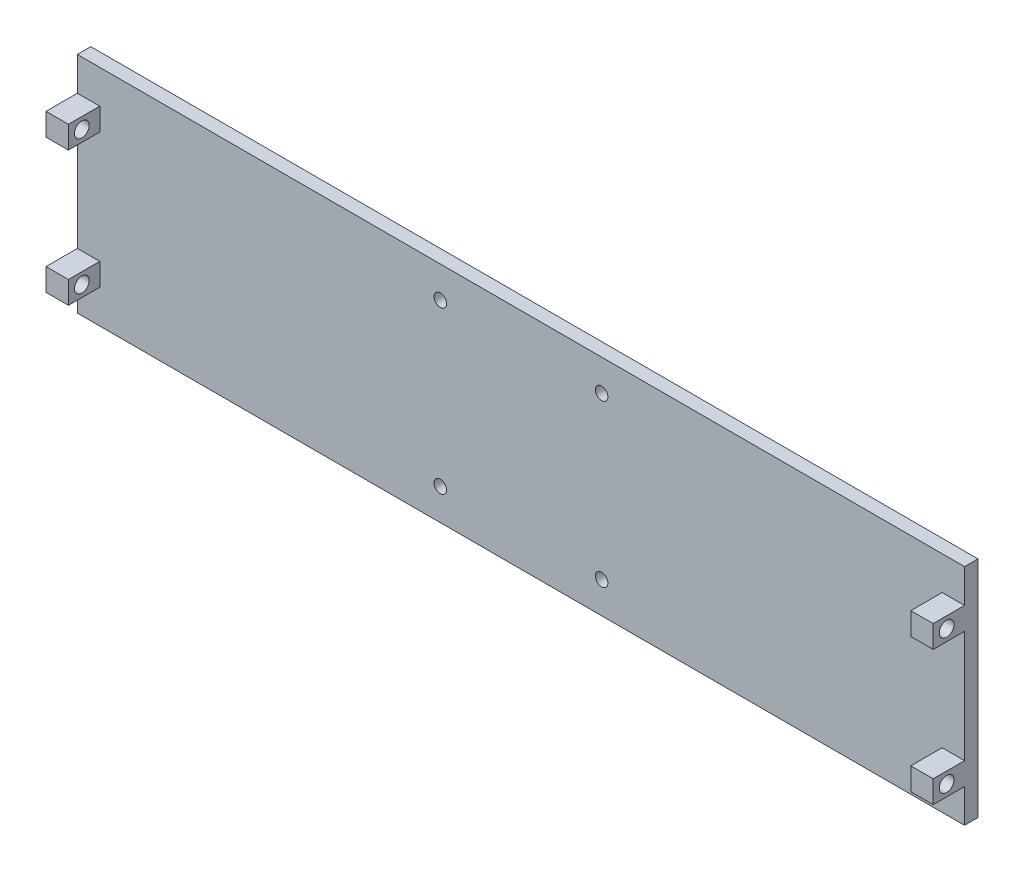
from build123d import *

# Parameters (mm, degrees)
SKETCH_1_W          = 198
SKETCH_1_H          = 50
EXTRUDE_1_DEPTH     = 3
SKETCH_4_W          = 10
SKETCH_4_H          = 5
SKETCH_4_R          = 1.65
EXTRUDE_2_DEPTH     = 5
SKETCH_5_W          = 10
SKETCH_5_H          = 5
SKETCH_5_R          = 1.65
EXTRUDE_3_DEPTH     = 5
SKETCH_6_R          = 1.4
CUT_EXTRUDE_3_DEPTH = 3


with BuildPart() as part:
    # 草图1 → 凸台-拉伸1 (new body)
    with BuildSketch(Plane.XY):
        Rectangle(SKETCH_1_W, SKETCH_1_H)
    extrude(amount=EXTRUDE_1_DEPTH)

    # 草图4 → 凸台-拉伸2 (add)
    with BuildSketch(Plane.ZY.offset(99)):
        with Locations((5, 15)):
            Rectangle(SKETCH_4_W, SKETCH_4_H)
        with Locations((7, 15)):
            Circle(SKETCH_4_R, mode=Mode.SUBTRACT)
        with Locations((5, -15)):
            Rectangle(SKETCH_4_W, SKETCH_4_H)
        with Locations((7, -15)):
            Circle(SKETCH_4_R, mode=Mode.SUBTRACT)
    extrude(amount=-EXTRUDE_2_DEPTH)

    # 草图5 → 凸台-拉伸3 (add)
    with BuildSketch(Plane(origin=(99, 0, 0), x_dir=(0, 0, -1), z_dir=(1, 0, 0))):
        with Locations((-5, 15)):
            Rectangle(SKETCH_5_W, SKETCH_5_H)
        with Locations((-7, 15)):
            Circle(SKETCH_5_R, mode=Mode.SUBTRACT)
        with Locations((-5, -15)):
            Rectangle(SKETCH_5_W, SKETCH_5_H)
        with Locations((-7, -15)):
            Circle(SKETCH_5_R, mode=Mode.SUBTRACT)
    extrude(amount=-EXTRUDE_3_DEPTH)

    # 草图6 → 切除-拉伸3 (cut)
    with BuildSketch(Plane.XY.offset(3)):
        with Locations((-18, 18)):
            Circle(SKETCH_6_R)
        with Locations((18, 18)):
            Circle(SKETCH_6_R)
        with Locations((18, -18)):
            Circle(SKETCH_6_R)
        with Locations((-18, -18)):
            Circle(SKETCH_6_R)
    extrude(amount=-CUT_EXTRUDE_3_DEPTH, mode=Mode.SUBTRACT)


solid = part.part
